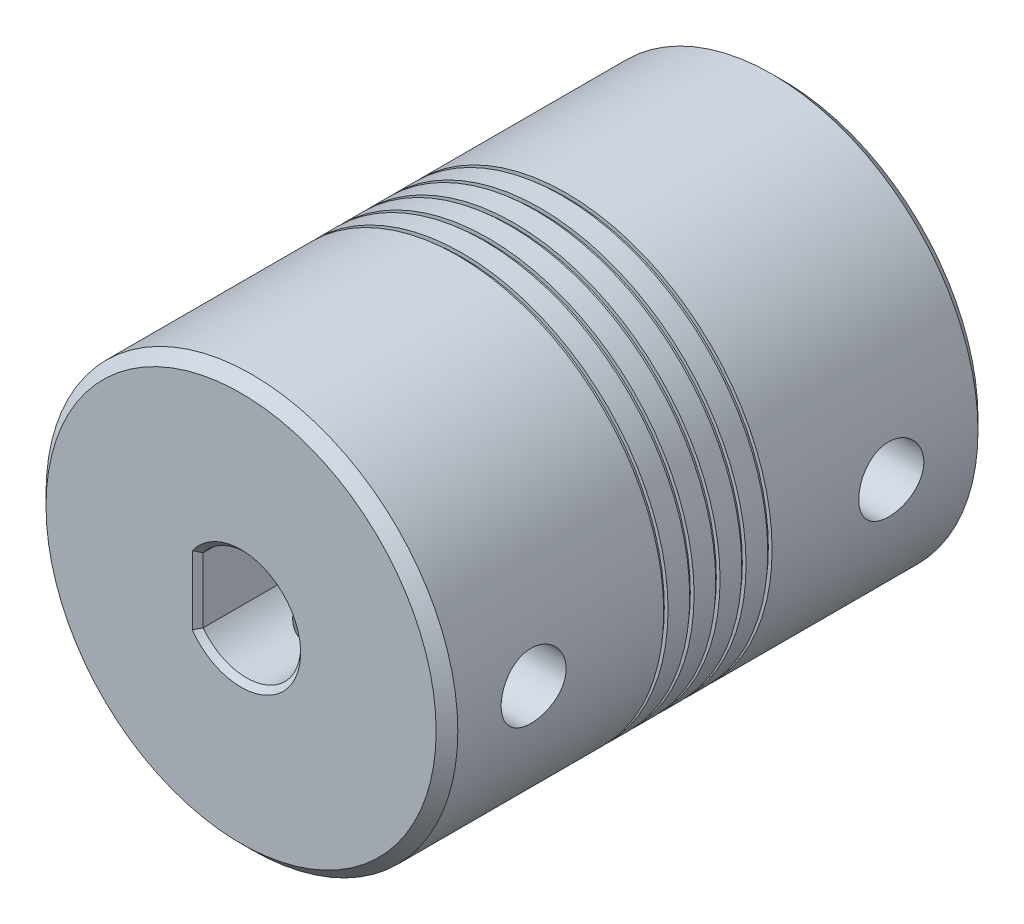
from build123d import *

# Parameters (mm, degrees)
IZIM1_R                     = 9.5
Y_KSEKLIK_EKSTR_ZYON1_DEPTH = 25
KES_EKSTR_ZYON1_DEPTH       = 26
IZIM3_R                     = 4
KES_EKSTR_ZYON2_DEPTH       = 10
PAH1_SIZE                   = 0.5
PAH2_SIZE                   = 0.25
IZIM4_W                     = 0.464141993
IZIM4_H                     = 0.2
KES_EKSTR_ZYON3_REACH       = 21
IZIM5_R                     = 1.5
KES_EKSTR_ZYON4_REACH       = 21
IZIM6_R                     = 1.5


with BuildPart() as part:
    # Çizim1 → Yükseklik-Ekstrüzyon1 (new body)
    with BuildSketch(Plane.XY):
        Circle(IZIM1_R)
    extrude(amount=Y_KSEKLIK_EKSTR_ZYON1_DEPTH)

    # Çizim2 → Kes-Ekstrüzyon1 (cut, through all)
    with BuildSketch(Plane.XY.offset(25)):
        with BuildLine():
            Line((-2, -1.5), (-2, 1.5))
            ThreePointArc((-2, 1.5), (2.5, 0), (-2, -1.5))
        make_face()
    extrude(amount=-KES_EKSTR_ZYON1_DEPTH, mode=Mode.SUBTRACT)

    # Çizim3 → Kes-Ekstrüzyon2 (cut)
    with BuildSketch(Plane(origin=(0, 0, 0), x_dir=(-1, 0, 0), z_dir=(0, 0, -1))):
        Circle(IZIM3_R)
    extrude(amount=-KES_EKSTR_ZYON2_DEPTH, mode=Mode.SUBTRACT)

    # Pah1
    pah1_edges = [part.edges().sort_by_distance(p)[0] for p in [
        (-9.5, 0, 0),
        (-9.5, 0, 25),
    ]]
    chamfer(pah1_edges, length=PAH1_SIZE)

    # Pah2
    pah2_edges = [part.edges().sort_by_distance(p)[0] for p in [
        (4, 0, 0),
        (2.5, 0, 25),
        (-2, 0, 25),
    ]]
    chamfer(pah2_edges, length=PAH2_SIZE)

    # Çizim4 → Kes-Döndür1 (revolve, cut)
    with BuildSketch(Plane(origin=(0, 0, 0), x_dir=(1, 0, 0), z_dir=(0, 1, 0))):
        with Locations((-9.559924432, -10.1)):
            Rectangle(IZIM4_W, IZIM4_H)
        with Locations((-9.559924432, -11.3)):
            Rectangle(IZIM4_W, IZIM4_H)
        with Locations((-9.559924432, -12.5)):
            Rectangle(IZIM4_W, IZIM4_H)
        with Locations((-9.559924432, -13.7)):
            Rectangle(IZIM4_W, IZIM4_H)
        with Locations((-9.559924432, -14.9)):
            Rectangle(IZIM4_W, IZIM4_H)
    revolve(axis=Axis((0, 0, -4.873321604), (0, 0, 1)), mode=Mode.SUBTRACT)

    # Çizim5 → Kes-Ekstrüzyon3 (cut, up to next)
    with BuildSketch(Plane(origin=(0, -9.5, 0), x_dir=(-1, 0, 0), z_dir=(0, -1, 0)), mode=Mode.PRIVATE) as kes_ekstr_zyon3_sk1:
        with Locations((0, -20.5)):
            Circle(IZIM5_R)
    kes_ekstr_zyon3_tool1 = extrude(kes_ekstr_zyon3_sk1.sketch, amount=-KES_EKSTR_ZYON3_REACH, mode=Mode.PRIVATE) & part.part
    add(kes_ekstr_zyon3_tool1.solids().sort_by_distance((0, -9.5, 20.5))[0], mode=Mode.SUBTRACT)
    # Çizim5 → Kes-Ekstrüzyon3 (cut, up to next)
    with BuildSketch(Plane(origin=(0, -9.5, 0), x_dir=(-1, 0, 0), z_dir=(0, -1, 0)), mode=Mode.PRIVATE) as kes_ekstr_zyon3_sk2:
        with Locations((0, -4)):
            Circle(IZIM5_R)
    kes_ekstr_zyon3_tool2 = extrude(kes_ekstr_zyon3_sk2.sketch, amount=-KES_EKSTR_ZYON3_REACH, mode=Mode.PRIVATE) & part.part
    add(kes_ekstr_zyon3_tool2.solids().sort_by_distance((0, -9.5, 4))[0], mode=Mode.SUBTRACT)

    # Çizim6 → Kes-Ekstrüzyon4 (cut, up to next)
    with BuildSketch(Plane(origin=(9.5, 0, 0), x_dir=(0, 0, -1), z_dir=(1, 0, 0)), mode=Mode.PRIVATE) as kes_ekstr_zyon4_sk1:
        with Locations((-21, 0)):
            Circle(IZIM6_R)
    kes_ekstr_zyon4_tool1 = extrude(kes_ekstr_zyon4_sk1.sketch, amount=-KES_EKSTR_ZYON4_REACH, mode=Mode.PRIVATE) & part.part
    add(kes_ekstr_zyon4_tool1.solids().sort_by_distance((9.5, 0, 21))[0], mode=Mode.SUBTRACT)
    # Çizim6 → Kes-Ekstrüzyon4 (cut, up to next)
    with BuildSketch(Plane(origin=(9.5, 0, 0), x_dir=(0, 0, -1), z_dir=(1, 0, 0)), mode=Mode.PRIVATE) as kes_ekstr_zyon4_sk2:
        with Locations((-4.5, 0)):
            Circle(IZIM6_R)
    kes_ekstr_zyon4_tool2 = extrude(kes_ekstr_zyon4_sk2.sketch, amount=-KES_EKSTR_ZYON4_REACH, mode=Mode.PRIVATE) & part.part
    add(kes_ekstr_zyon4_tool2.solids().sort_by_distance((9.5, 0, 4.5))[0], mode=Mode.SUBTRACT)


solid = part.part
